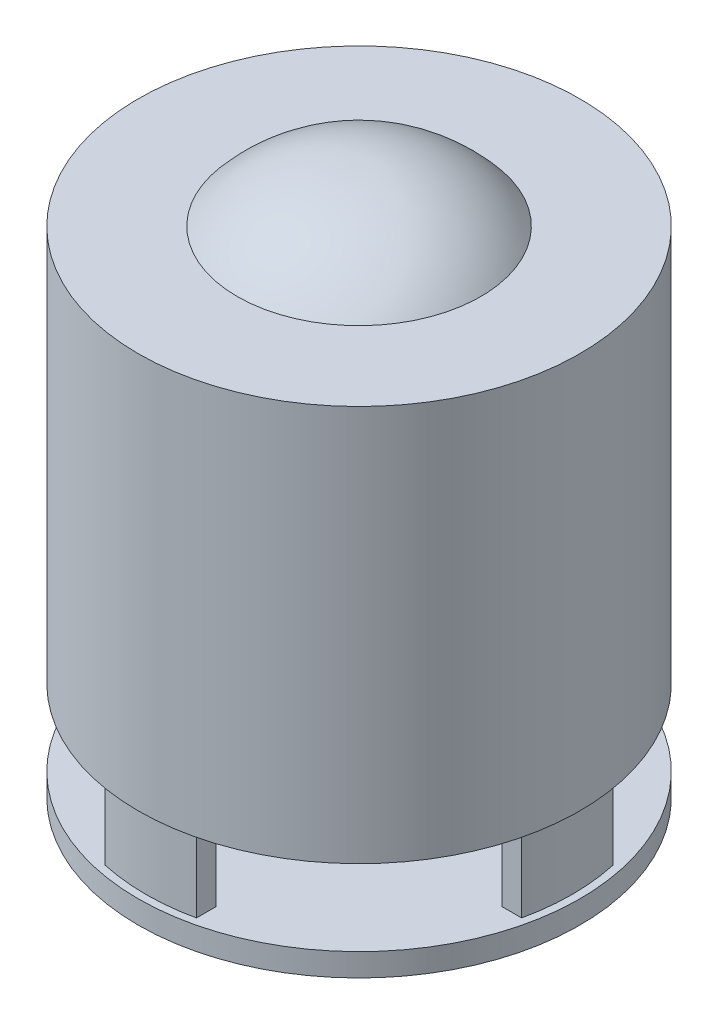
from build123d import *

# Parameters (mm, degrees)
SKETCH1_R           = 29
BOSS_EXTRUDE1_DEPTH = 3
BOSS_EXTRUDE2_DEPTH = 10
SKETCH3_R           = 29
BOSS_EXTRUDE3_DEPTH = 52
SKETCH5_R           = 2.05
CUT_EXTRUDE1_DEPTH  = 5


with BuildPart() as part:
    # Sketch1 → Boss-Extrude1 (new body)
    with BuildSketch(Plane(origin=(0, 0, 0), x_dir=(1, 0, 0), z_dir=(0, 1, 0))):
        Circle(SKETCH1_R)
    extrude(amount=BOSS_EXTRUDE1_DEPTH)

    # Sketch2 → Boss-Extrude2 (add)
    with BuildSketch(Plane(origin=(0, 3, 0), x_dir=(1, 0, 0), z_dir=(0, 1, 0))):
        with BuildLine():
            ThreePointArc((-27.349588662, 6), (-28, 0), (-27.349588662, -6))
            Line((-27.349588662, -6), (-24.784067463, -6))
            ThreePointArc((-24.784067463, -6), (-25.5, 0), (-24.784067463, 6))
            Line((-24.784067463, 6), (-27.349588662, 6))
        make_face()
        with BuildLine():
            Line((24.784067463, -6), (27.349588662, -6))
            ThreePointArc((27.349588662, -6), (27.836922267, -3.017574975), (28, 0))
            ThreePointArc((28, 0), (27.836922267, 3.017574975), (27.349588662, 6))
            Line((27.349588662, 6), (24.784067463, 6))
            ThreePointArc((24.784067463, 6), (25.320384281, 3.02128116), (25.5, 0))
            ThreePointArc((25.5, 0), (25.320384281, -3.02128116), (24.784067463, -6))
        make_face()
        with BuildLine():
            Line((-6, -24.784067463), (-6, -27.349588662))
            ThreePointArc((-6, -27.349588662), (0, -28), (6, -27.349588662))
            Line((6, -27.349588662), (6, -24.784067463))
            ThreePointArc((6, -24.784067463), (0, -25.5), (-6, -24.784067463))
        make_face()
        with BuildLine():
            ThreePointArc((6, 27.349588662), (0, 28), (-6, 27.349588662))
            Line((-6, 27.349588662), (-6, 24.784067463))
            ThreePointArc((-6, 24.784067463), (0, 25.5), (6, 24.784067463))
            Line((6, 24.784067463), (6, 27.349588662))
        make_face()
    extrude(amount=BOSS_EXTRUDE2_DEPTH)

    # Sketch3 → Boss-Extrude3 (add)
    with BuildSketch(Plane(origin=(0, 13, 0), x_dir=(1, 0, 0), z_dir=(0, 1, 0))):
        Circle(SKETCH3_R)
    extrude(amount=BOSS_EXTRUDE3_DEPTH)

    # Sketch4 → Revolve1 (revolve)
    with BuildSketch(Plane.XY):
        with BuildLine():
            Line((0, 65), (0, 72))
            ThreePointArc((0, 72), (8.804421669, 70.338678101), (16, 65))
            Line((16, 65), (0, 65))
        make_face()
    revolve(axis=Axis((0, 65, 0), (0, 1, 0)))

    # Sketch5 → Cut-Extrude1 (cut)
    with BuildSketch(Plane.XZ):
        with Locations((0, 12)):
            Circle(SKETCH5_R)
        with Locations((10.392304845, -6)):
            Circle(SKETCH5_R)
        with Locations((-10.392304845, -6)):
            Circle(SKETCH5_R)
    extrude(amount=-CUT_EXTRUDE1_DEPTH, mode=Mode.SUBTRACT)


solid = part.part
